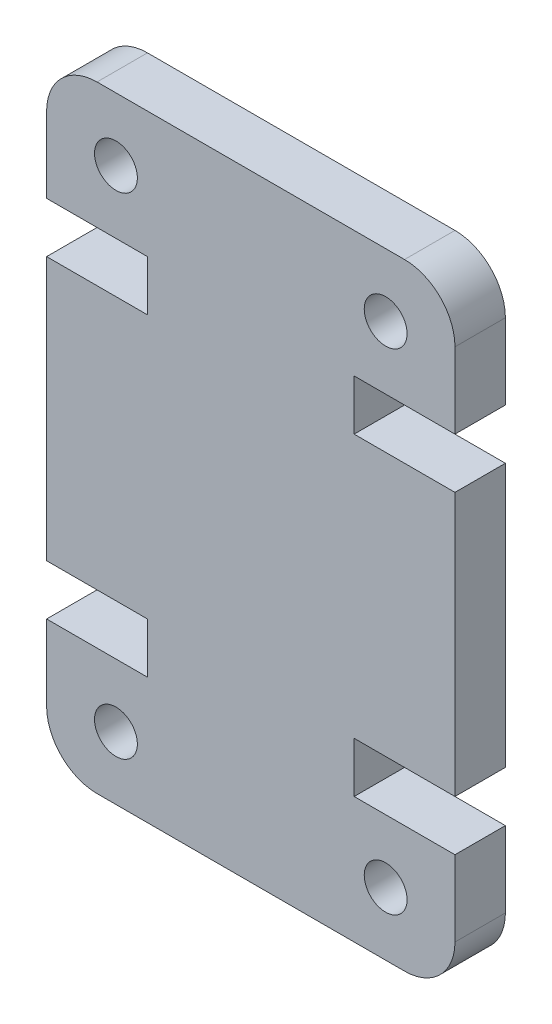
from build123d import *

# Parameters (mm, degrees)
SKETCH1_R           = 0.85
BOSS_EXTRUDE1_DEPTH = 4
SKETCH2_W           = 16.2
SKETCH2_H           = 24.45
CUT_EXTRUDE1_DEPTH  = 2


with BuildPart() as part:
    # Sketch1 → Boss-Extrude1 (new body)
    with BuildSketch(Plane.XY):
        with BuildLine():
            Line((0, 17.45), (0, 7))
            Line((0, 7), (4, 7))
            Line((4, 7), (4, 5))
            Line((4, 5), (0, 5))
            Line((0, 5), (0, 2))
            ThreePointArc((0, 2), (0.585786438, 0.585786438), (2, 0))
            Line((2, 0), (14.2, 0))
            ThreePointArc((14.2, 0), (15.614213562, 0.585786438), (16.2, 2))
            Line((16.2, 2), (16.2, 5))
            Line((16.2, 5), (12.2, 5))
            Line((12.2, 5), (12.2, 7))
            Line((12.2, 7), (16.2, 7))
            Line((16.2, 7), (16.2, 17.45))
            Line((16.2, 17.45), (12.2, 17.45))
            Line((12.2, 17.45), (12.2, 19.45))
            Line((12.2, 19.45), (16.2, 19.45))
            Line((16.2, 19.45), (16.2, 22.45))
            ThreePointArc((16.2, 22.45), (15.614213562, 23.864213562), (14.2, 24.45))
            Line((14.2, 24.45), (2, 24.45))
            ThreePointArc((2, 24.45), (0.585786438, 23.864213562), (0, 22.45))
            Line((0, 22.45), (0, 19.45))
            Line((0, 19.45), (4, 19.45))
            Line((4, 19.45), (4, 17.45))
            Line((4, 17.45), (0, 17.45))
        make_face()
        with Locations((13.45, 2.5)):
            Circle(SKETCH1_R, mode=Mode.SUBTRACT)
        with Locations((2.75, 21.95)):
            Circle(SKETCH1_R, mode=Mode.SUBTRACT)
        with Locations((2.75, 2.5)):
            Circle(SKETCH1_R, mode=Mode.SUBTRACT)
        with Locations((13.45, 21.95)):
            Circle(SKETCH1_R, mode=Mode.SUBTRACT)
    extrude(amount=BOSS_EXTRUDE1_DEPTH)

    # Sketch2 → Cut-Extrude1 (cut)
    with BuildSketch(Plane(origin=(0, 0, 0), x_dir=(-1, 0, 0), z_dir=(0, 0, -1))):
        with Locations((-8.1, 12.225)):
            Rectangle(SKETCH2_W, SKETCH2_H)
    extrude(amount=-CUT_EXTRUDE1_DEPTH, mode=Mode.SUBTRACT)


solid = part.part
